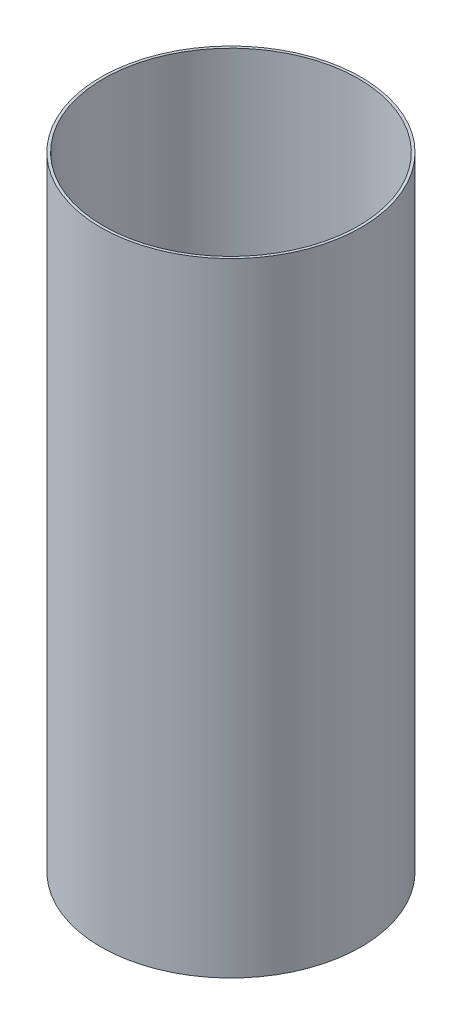
from build123d import *

# Parameters (mm, degrees)
SKETCH1_R           = 77.8637
SKETCH1_R_2         = 76.2889
BOSS_EXTRUDE1_DEPTH = 372.618


with BuildPart() as part:
    # Sketch1 → Boss-Extrude1 (new body)
    with BuildSketch(Plane(origin=(0, 0, 0), x_dir=(1, 0, 0), z_dir=(0, 1, 0))):
        Circle(SKETCH1_R)
        Circle(SKETCH1_R_2, mode=Mode.SUBTRACT)
    extrude(amount=BOSS_EXTRUDE1_DEPTH)


solid = part.part
